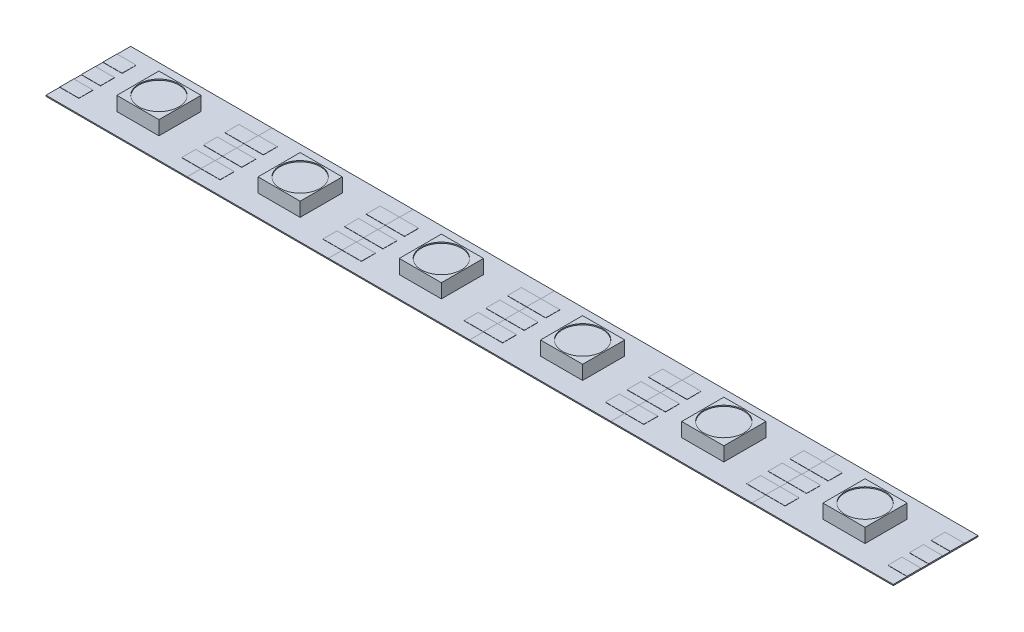
from build123d import *

# Parameters (mm, degrees)
SKETCH1_W           = 16.6116
SKETCH1_H           = 9.9568
BOSS_EXTRUDE1_DEPTH = 0.127
SKETCH3_W           = 4.953
SKETCH3_H           = 4.953
BOSS_EXTRUDE3_DEPTH = 1.651
SKETCH4_W           = 2.258810151
SKETCH4_H           = 1.651
BOSS_EXTRUDE4_DEPTH = 0.0254
SKETCH5_R           = 2.348345572
CUT_EXTRUDE1_DEPTH  = 0.127
LPATTERN1_COUNT     = 6
LPATTERN1_PITCH     = 16.6116


with BuildPart() as part:
    # Sketch1 → Boss-Extrude1 (new body)
    with BuildSketch(Plane(origin=(0, 0, 0), x_dir=(1, 0, 0), z_dir=(0, 1, 0))):
        Rectangle(SKETCH1_W, SKETCH1_H)
    extrude(amount=BOSS_EXTRUDE1_DEPTH)

    # Sketch3 → Boss-Extrude3 (add)
    with BuildSketch(Plane(origin=(0, 0.127, 0), x_dir=(1, 0, 0), z_dir=(0, 1, 0))):
        Rectangle(SKETCH3_W, SKETCH3_H)
    extrude(amount=BOSS_EXTRUDE3_DEPTH)

    # Sketch4 → Boss-Extrude4 (add)
    with BuildSketch(Plane(origin=(0, 0.127, 0), x_dir=(1, 0, 0), z_dir=(0, 1, 0))):
        with Locations((-7.176394925, 0)):
            Rectangle(SKETCH4_W, SKETCH4_H)
        with Locations((-7.176394925, 2.54)):
            Rectangle(SKETCH4_W, SKETCH4_H)
        with Locations((-7.176394925, -2.54)):
            Rectangle(SKETCH4_W, SKETCH4_H)
        with Locations((7.176394925, -2.54)):
            Rectangle(SKETCH4_W, SKETCH4_H)
        with Locations((7.176394925, 0)):
            Rectangle(SKETCH4_W, SKETCH4_H)
        with Locations((7.176394925, 2.54)):
            Rectangle(SKETCH4_W, SKETCH4_H)
    extrude(amount=BOSS_EXTRUDE4_DEPTH)

    # Sketch5 → Cut-Extrude1 (cut)
    with BuildSketch(Plane(origin=(0, 1.778, 0), x_dir=(1, 0, 0), z_dir=(0, 1, 0))):
        Circle(SKETCH5_R)
    extrude(amount=-CUT_EXTRUDE1_DEPTH, mode=Mode.SUBTRACT)


with BuildPart() as lpattern1_1:
    # LPattern1: pattern copy
    add(part.part.moved(Location(Vector(1, 0, 0) * (1 * LPATTERN1_PITCH))))


with BuildPart() as lpattern1_2:
    # LPattern1: pattern copy
    add(part.part.moved(Location(Vector(1, 0, 0) * (2 * LPATTERN1_PITCH))))


with BuildPart() as lpattern1_3:
    # LPattern1: pattern copy
    add(part.part.moved(Location(Vector(1, 0, 0) * (3 * LPATTERN1_PITCH))))


with BuildPart() as lpattern1_4:
    # LPattern1: pattern copy
    add(part.part.moved(Location(Vector(1, 0, 0) * (4 * LPATTERN1_PITCH))))


with BuildPart() as lpattern1_5:
    # LPattern1: pattern copy
    add(part.part.moved(Location(Vector(1, 0, 0) * (5 * LPATTERN1_PITCH))))


solid = Compound([part.part, lpattern1_1.part, lpattern1_2.part, lpattern1_3.part, lpattern1_4.part, lpattern1_5.part])
